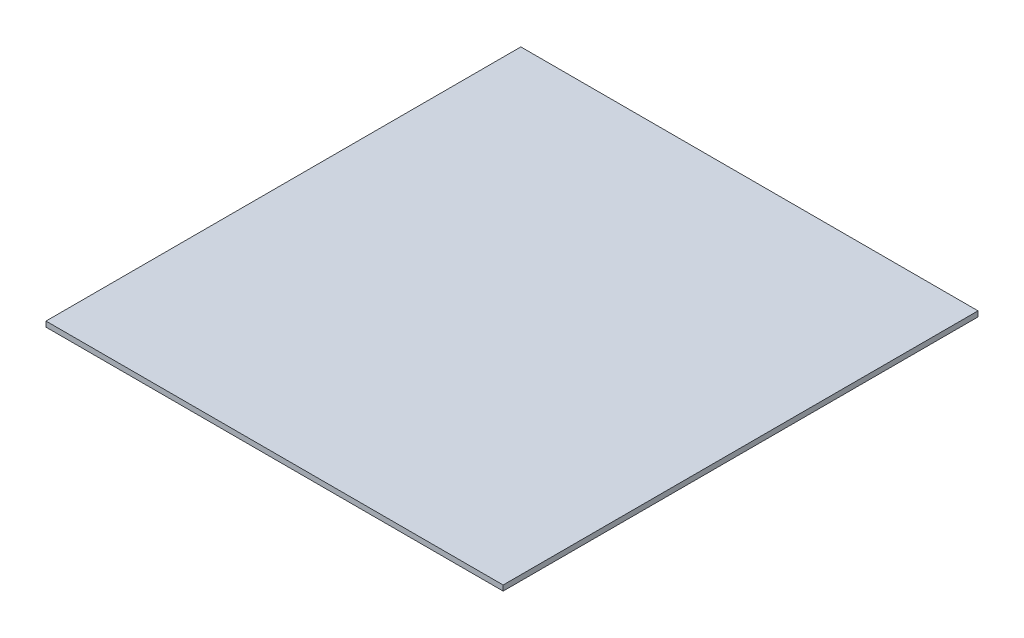
from build123d import *

# Parameters (mm, degrees)
SKETCH1_W           = 125
SKETCH1_H           = 130
BOSS_EXTRUDE1_DEPTH = 0.6
SKETCH2_W           = 129
SKETCH2_H           = 134
BOSS_EXTRUDE2_DEPTH = 1.5


with BuildPart() as part:
    # Sketch1 → Boss-Extrude1 (new body)
    with BuildSketch(Plane(origin=(0, 30, 0), x_dir=(1, 0, 0), z_dir=(0, 1, 0))):
        with Locations((62.5, 65)):
            Rectangle(SKETCH1_W, SKETCH1_H)
    extrude(amount=-BOSS_EXTRUDE1_DEPTH)

    # Sketch2 → Boss-Extrude2 (add)
    with BuildSketch(Plane(origin=(0, 30, 0), x_dir=(1, 0, 0), z_dir=(0, 1, 0))):
        with Locations((62.5, 65)):
            Rectangle(SKETCH2_W, SKETCH2_H)
    extrude(amount=BOSS_EXTRUDE2_DEPTH)


solid = part.part
